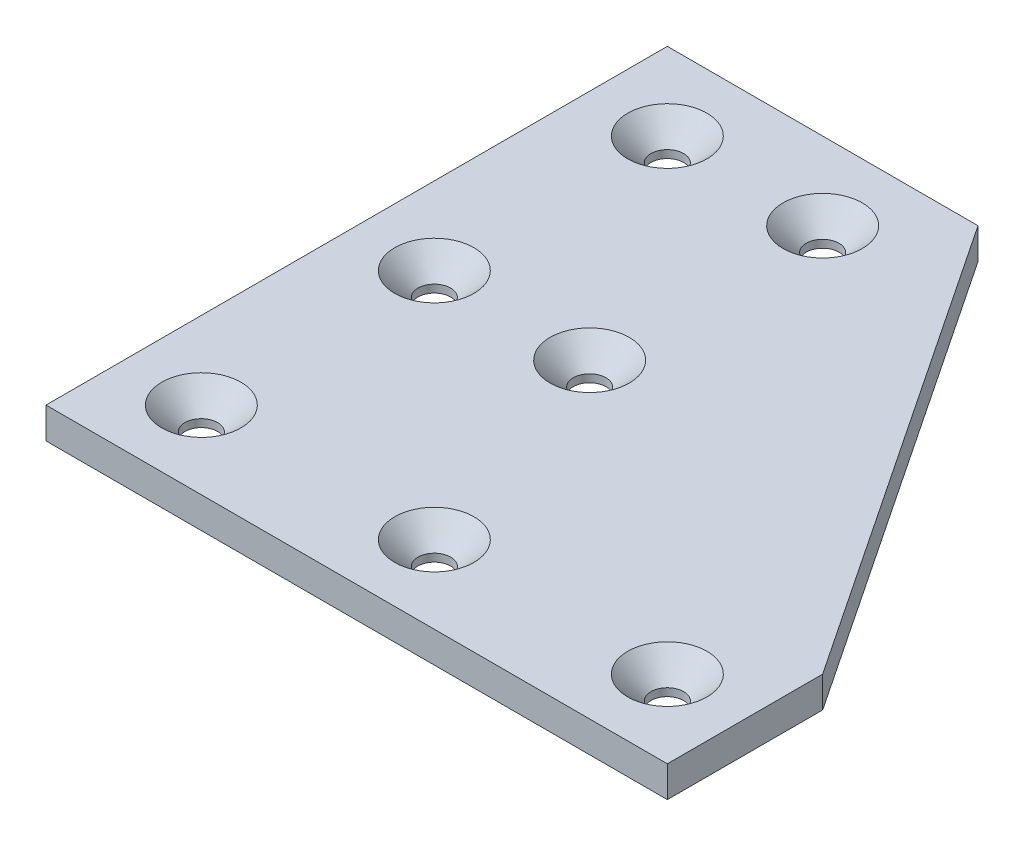
from build123d import *

# Parameters (mm, degrees)
BOSS_EXTRUDE1_DEPTH = 4
SKETCH2_R           = 2.1
CUT_EXTRUDE1_DEPTH  = 4
CHAMFER1_SIZE       = 3


with BuildPart() as part:
    # Sketch1 → Boss-Extrude1 (new body)
    with BuildSketch(Plane(origin=(0, 0, 0), x_dir=(1, 0, 0), z_dir=(0, 1, 0))):
        Polygon((0, 0), (80, 0), (80, 20), (40, 80), (0, 80), align=None)
    extrude(amount=BOSS_EXTRUDE1_DEPTH)

    # Sketch2 → Cut-Extrude1 (cut)
    with BuildSketch(Plane(origin=(0, 4, 0), x_dir=(1, 0, 0), z_dir=(0, 1, 0))):
        with Locations((10, 10)):
            Circle(SKETCH2_R)
        with Locations((40, 10)):
            Circle(SKETCH2_R)
        with Locations((70, 10)):
            Circle(SKETCH2_R)
        with Locations((30, 40)):
            Circle(SKETCH2_R)
        with Locations((30, 70)):
            Circle(SKETCH2_R)
        with Locations((10, 40)):
            Circle(SKETCH2_R)
        with Locations((10, 70)):
            Circle(SKETCH2_R)
    extrude(amount=-CUT_EXTRUDE1_DEPTH, mode=Mode.SUBTRACT)

    # Chamfer1
    chamfer1_edges = [part.edges().sort_by_distance(p)[0] for p in [
        (7.9, 4, -70),
        (7.9, 4, -40),
        (27.9, 4, -70),
        (27.9, 4, -40),
        (67.9, 4, -10),
        (37.9, 4, -10),
        (7.9, 4, -10),
    ]]
    chamfer(chamfer1_edges, length=CHAMFER1_SIZE)


solid = part.part
